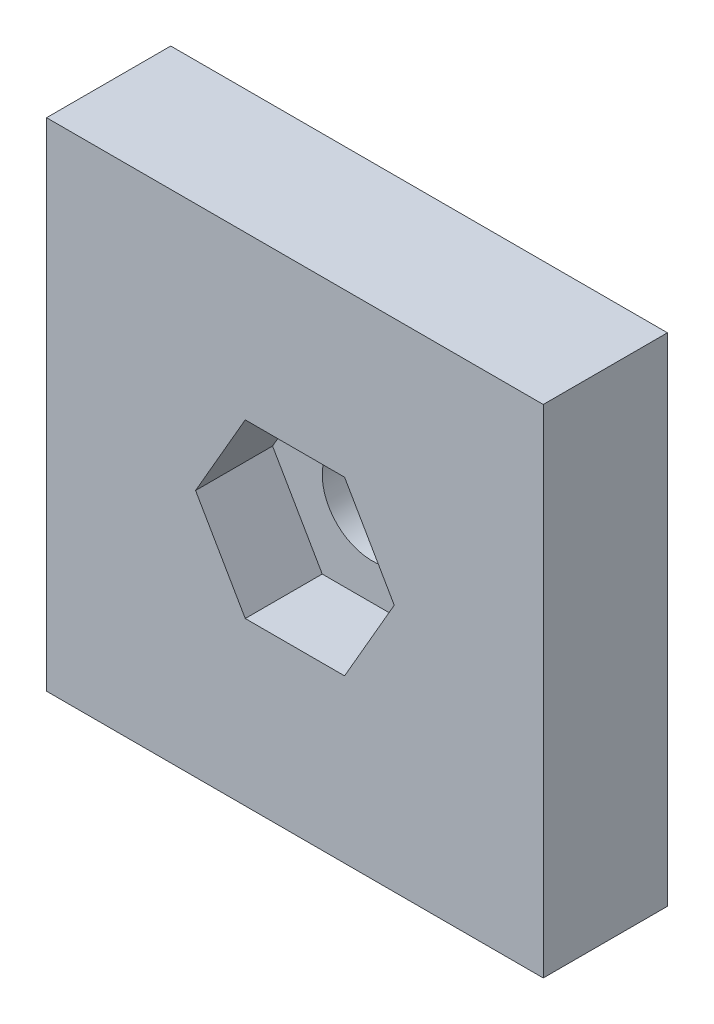
from build123d import *

# Parameters (mm, degrees)
SKETCH1_W           = 20
SKETCH1_H           = 20
BOSS_EXTRUDE1_DEPTH = 5
CUT_EXTRUDE1_DEPTH  = 3.1
SKETCH4_R           = 2
CUT_EXTRUDE2_DEPTH  = 6


with BuildPart() as part:
    # Sketch1 → Boss-Extrude1 (new body)
    with BuildSketch(Plane.XY):
        with Locations((-10, 10)):
            Rectangle(SKETCH1_W, SKETCH1_H)
    extrude(amount=BOSS_EXTRUDE1_DEPTH)

    # Sketch2 → Cut-Extrude1 (cut)
    with BuildSketch(Plane.XY.offset(5)):
        Polygon((-6, 10), (-8, 13.464101615), (-12, 13.464101615), (-14, 10), (-12, 6.535898385), (-8, 6.535898385), align=None)
    extrude(amount=-CUT_EXTRUDE1_DEPTH, mode=Mode.SUBTRACT)

    # Sketch4 → Cut-Extrude2 (cut, through all)
    with BuildSketch(Plane.XY.offset(5)):
        with Locations((-10, 10)):
            Circle(SKETCH4_R)
    extrude(amount=-CUT_EXTRUDE2_DEPTH, mode=Mode.SUBTRACT)


solid = part.part
